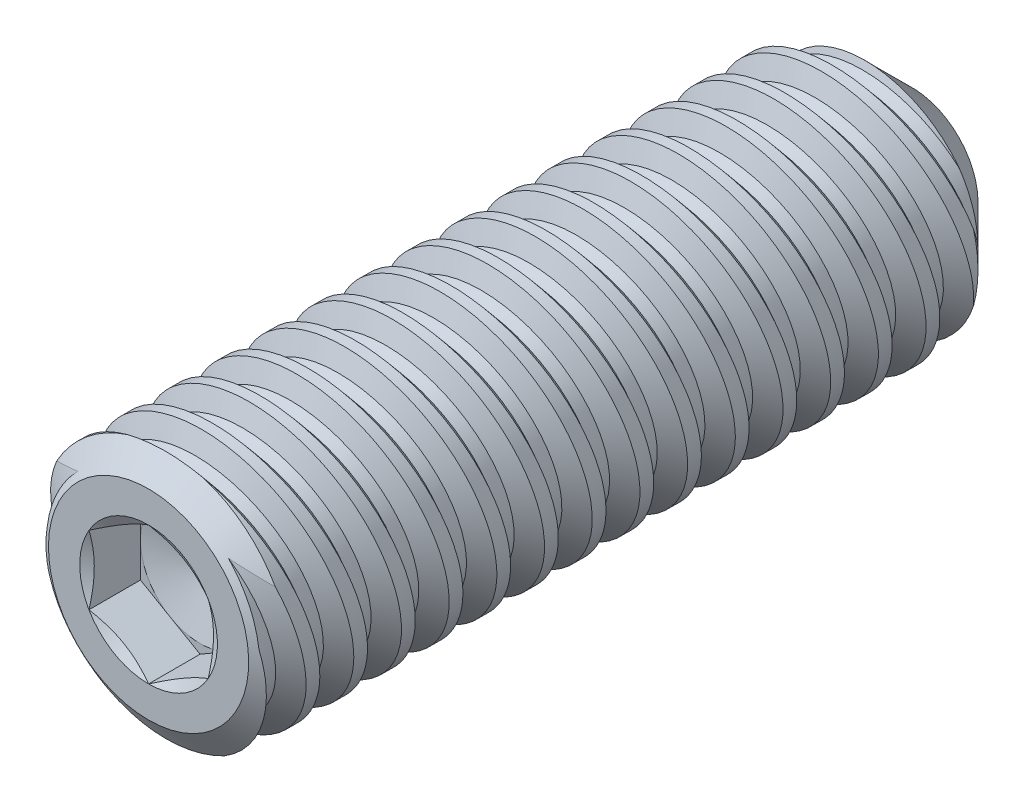
from build123d import *

# Parameters (mm, degrees)
LPATTERN1_COUNT     = 15
LPATTERN1_PITCH     = 0.79375
LPATTERN1_COL_COUNT = 2
LPATTERN1_COL_PITCH = 0.79375
CUT_EXTRUDE10_DEPTH = 0.85725


with BuildPart() as part:
    # Sketch22 → Revolve1 (revolve)
    with BuildSketch(Plane(origin=(0, 0, 0), x_dir=(0, 0, -1), z_dir=(1, 0, 0)), mode=Mode.PRIVATE) as revolve1_sk:
        Polygon((-6.35, 0), (-6.35, 1.66624), (-6.058321548, 2.0828), (5.3721, 2.0828), (6.35, 1.1049), (6.35, 0), align=None)
    revolve(revolve1_sk.sketch.rotate(Axis((0, 0, -5.686109102), (0, 0, -1)), 180), axis=Axis((0, 0, -5.686109102), (0, 0, -1)))

    # Sketch6 → Cut-Revolve8 (revolve, cut)
    with BuildSketch(Plane(origin=(0, 0, 0), x_dir=(0, 0, -1), z_dir=(1, 0, 0))):
        Polygon((4.740308802, 1.762908932), (4.545378594, 1.725765218), (4.221297335, 2.101371857), (4.903553063, 2.231374854), align=None)
    cut_revolve8 = revolve(axis=Axis((0, 0.162231854, -5.826617769), (0, -0.18718091792155486, 0.9823254572523529)), mode=Mode.SUBTRACT)

    # LPattern1: Cut-Revolve8 ×15
    with Locations(*[(0, 0, i * LPATTERN1_PITCH) for i in range(1, LPATTERN1_COUNT)]):
        add(cut_revolve8, mode=Mode.SUBTRACT)

    # LPattern1 col: Cut-Revolve8 ×2
    with Locations(*[(0, 0, -i * LPATTERN1_COL_PITCH) for i in range(1, LPATTERN1_COL_COUNT)]):
        add(cut_revolve8, mode=Mode.SUBTRACT)

    # Sketch23 → Cut-Extrude10 (cut)
    with BuildSketch(Plane.XY.offset(6.35)):
        Polygon((0, 1.14567944), (-0.9921875, 0.57283972), (-0.9921875, -0.57283972), (0, -1.14567944), (0.9921875, -0.57283972), (0.9921875, 0.57283972), align=None)
    extrude(amount=-CUT_EXTRUDE10_DEPTH, mode=Mode.SUBTRACT)

    # Cut-Extrude11 cone 1 section (through the dimple's axis) → Cut-Extrude11 (revolve, cut)
    with BuildSketch(Plane(origin=(0, 0, 6.35), x_dir=(0, -1, 0), z_dir=(1, 0, 0))):
        Polygon((0, 0), (1.14567944, 0), (0, 0.661458333), align=None)
    revolve(axis=Axis((0, 0, 6.35), (0, 0, -1)), mode=Mode.SUBTRACT)

    # Cut-Extrude12 cone 1 section (through the dimple's axis) → Cut-Extrude12 (revolve, cut)
    with BuildSketch(Plane(origin=(0, 0, 5.49275), x_dir=(0, -1, 0), z_dir=(1, 0, 0))):
        Polygon((0, 0), (0.9921875, 0), (0, 0.265855839), align=None)
    revolve(axis=Axis((0, 0, 5.49275), (0, 0, -1)), mode=Mode.SUBTRACT)


solid = part.part
